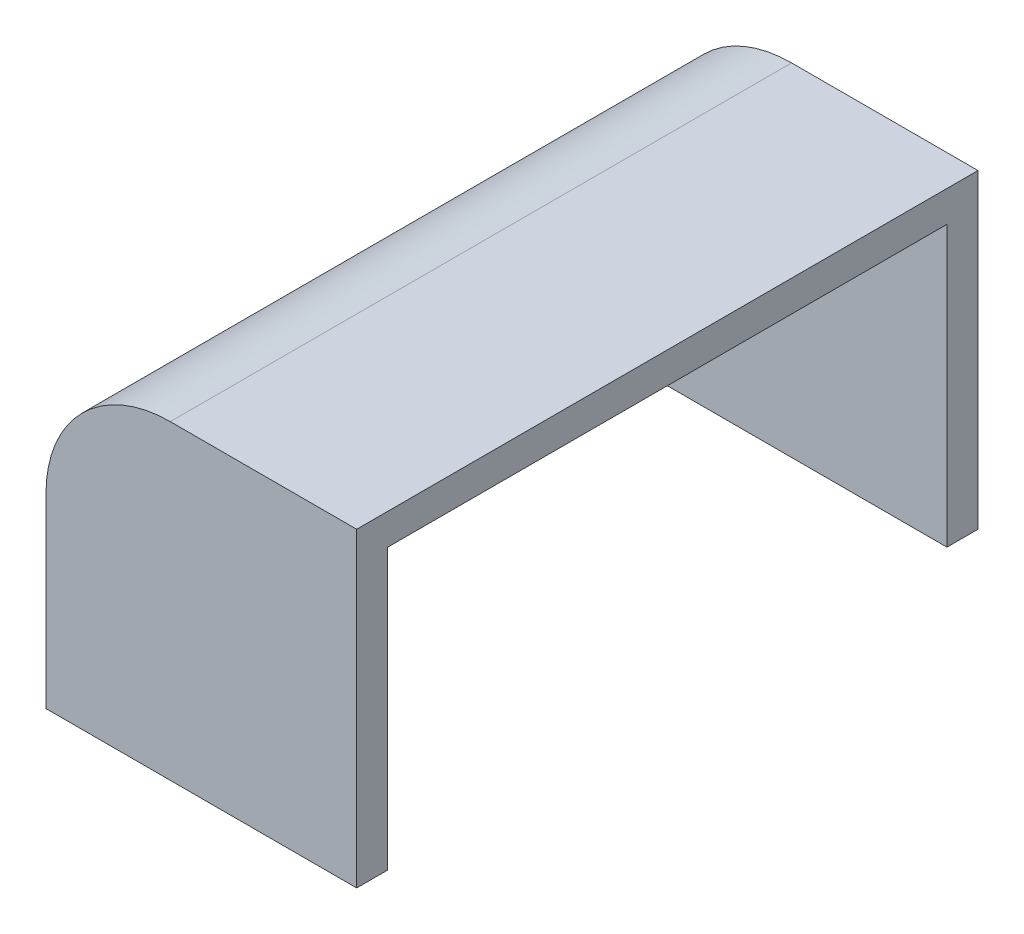
from build123d import *

# Parameters (mm, degrees)
BOSS_EXTRU_1_DEPTH = 9
BOSS_EXTRU_2_DEPTH = 0.5
BOSS_EXTRU_3_DEPTH = 0.5


with BuildPart() as part:
    # Esquisse1 → Boss.-Extru.1 (new body)
    with BuildSketch(Plane.XY):
        with BuildLine():
            Line((-5, 0), (-5, 3))
            ThreePointArc((-5, 3), (-4.414213562, 4.414213562), (-3, 5))
            Line((-3, 5), (0, 5))
            Line((0, 5), (0, 4.5))
            Line((0, 4.5), (-2.5, 4.5))
            ThreePointArc((-2.5, 4.5), (-3.914213562, 3.914213562), (-4.5, 2.5))
            Line((-4.5, 2.5), (-4.5, 0))
            Line((-4.5, 0), (-5, 0))
        make_face()
    extrude(amount=BOSS_EXTRU_1_DEPTH)

    # Esquisse2 → Boss.-Extru.2 (add)
    with BuildSketch(Plane.XY.offset(9)):
        with BuildLine():
            Line((0, 5), (0, 0))
            Line((0, 0), (-5, 0))
            Line((-5, 0), (-5, 3))
            ThreePointArc((-5, 3), (-4.414213562, 4.414213562), (-3, 5))
            Line((-3, 5), (0, 5))
        make_face()
    extrude(amount=BOSS_EXTRU_2_DEPTH)

    # Esquisse3 → Boss.-Extru.3 (add)
    with BuildSketch(Plane(origin=(0, 0, 0), x_dir=(-1, 0, 0), z_dir=(0, 0, -1))):
        with BuildLine():
            Line((0, 5), (3, 5))
            ThreePointArc((3, 5), (4.414213562, 4.414213562), (5, 3))
            Line((5, 3), (5, 0))
            Line((5, 0), (0, 0))
            Line((0, 0), (0, 5))
        make_face()
    extrude(amount=BOSS_EXTRU_3_DEPTH)


solid = part.part
